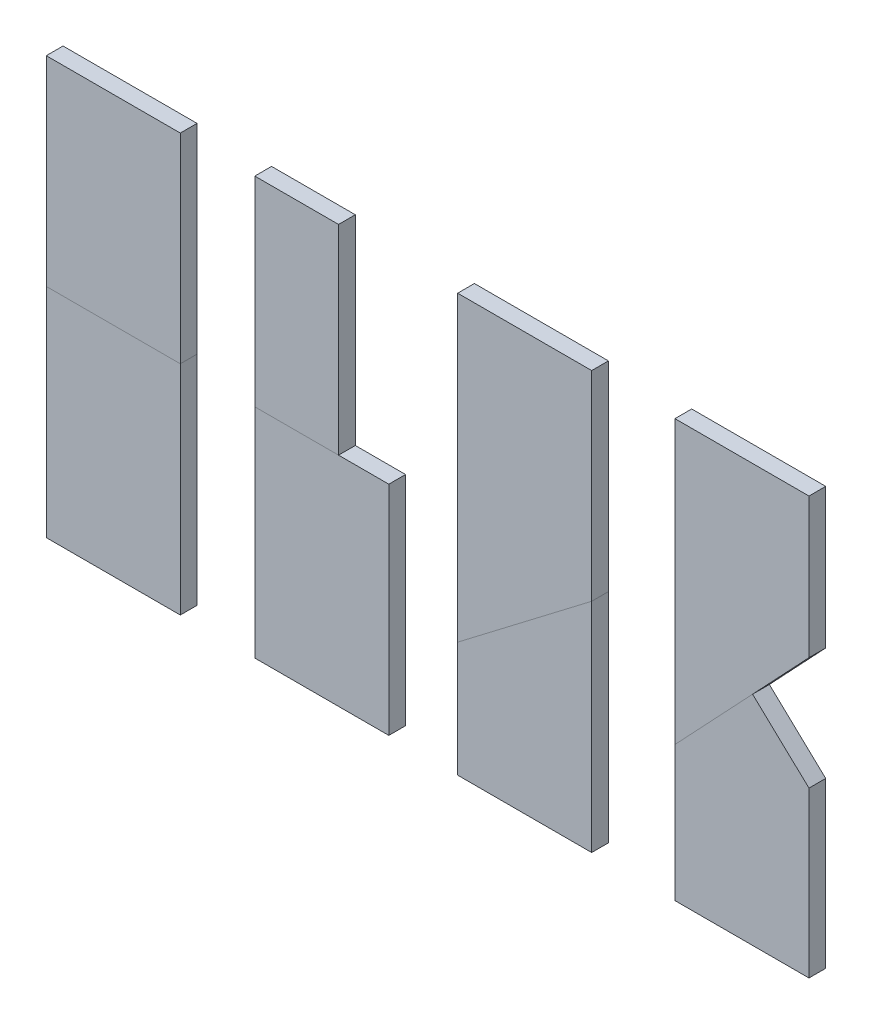
from build123d import *

# Parameters (mm, degrees)
ESQUISSE11_W                  = 40
ESQUISSE11_H                  = 5
EL_MENT_M_CANO_SOUD_1_DEPTH   = 59.639969087
ESQUISSE11_ON_SEGMENT_2_W     = 40
ESQUISSE11_ON_SEGMENT_2_H     = 5
EL_MENT_M_CANO_SOUD_1_2_DEPTH = 64.941299673
ESQUISSE12_W                  = 40
ESQUISSE12_H                  = 5
EL_MENT_M_CANO_SOUD_2_DEPTH   = 64.941299673
ESQUISSE14_W                  = 25
ESQUISSE14_H                  = 5
EL_MENT_M_CANO_SOUD_3_DEPTH   = 59.639969087
ESQUISSE15_W                  = 40
ESQUISSE15_H                  = 5
EL_MENT_M_CANO_SOUD_4_DEPTH   = 59.639969087
ESQUISSE15_ON_SEGMENT_2_W     = 40
ESQUISSE15_ON_SEGMENT_2_H     = 5
EL_MENT_M_CANO_SOUD_4_2_DEPTH = 64.941299673
ESQUISSE16_W                  = 40
ESQUISSE16_H                  = 5
EL_MENT_M_CANO_SOUD_5_DEPTH   = 59.639969087
ESQUISSE16_ON_SEGMENT_2_W     = 40
ESQUISSE16_ON_SEGMENT_2_H     = 5
EL_MENT_M_CANO_SOUD_5_2_DEPTH = 64.941299673
ENL_V_MAT_EXTRU_1_DEPTH       = 6
BOSS_EXTRU_1_DEPTH            = 5
ENL_V_MAT_EXTRU_3_DEPTH       = 6
BOSS_EXTRU_3_DEPTH            = 5


with BuildPart() as part:
    # Esquisse11 → El_ment m_cano-soud_1 (new body)
    with BuildSketch(Plane(origin=(-88.443865269, 59.639969087, 0), x_dir=(1, 0, 0), z_dir=(0, -1, 0))):
        Rectangle(ESQUISSE11_W, ESQUISSE11_H)
    extrude(amount=EL_MENT_M_CANO_SOUD_1_DEPTH)


with BuildPart() as body_2:
    # Esquisse11 on segment 2 (carried to segment 2) → El_ment m_cano-soud_1 2 (new body)
    with BuildSketch(Plane(origin=(-88.443865269, 0, 0), x_dir=(1, 0, 0), z_dir=(0, -1, 0))):
        Rectangle(ESQUISSE11_ON_SEGMENT_2_W, ESQUISSE11_ON_SEGMENT_2_H)
    extrude(amount=EL_MENT_M_CANO_SOUD_1_2_DEPTH)


with BuildPart() as body_3:
    # Esquisse12 → El_ment m_cano-soud_2 (new body)
    with BuildSketch(Plane(origin=(-26.209931604, -64.941299673, 0), x_dir=(-1, 0, 0), z_dir=(0, 1, 0))):
        Rectangle(ESQUISSE12_W, ESQUISSE12_H)
    extrude(amount=EL_MENT_M_CANO_SOUD_2_DEPTH)


with BuildPart() as body_4:
    # Esquisse14 → El_ment m_cano-soud_3 (new body)
    with BuildSketch(Plane(origin=(-33.709931604, 0, 0), x_dir=(-1, 0, 0), z_dir=(0, 1, 0))):
        Rectangle(ESQUISSE14_W, ESQUISSE14_H)
    extrude(amount=EL_MENT_M_CANO_SOUD_3_DEPTH)


with BuildPart() as body_5:
    # Esquisse15 → El_ment m_cano-soud_4 (new body)
    with BuildSketch(Plane(origin=(34.333341249, 59.639969087, 0), x_dir=(1, 0, 0), z_dir=(0, -1, 0))):
        Rectangle(ESQUISSE15_W, ESQUISSE15_H)
    extrude(amount=EL_MENT_M_CANO_SOUD_4_DEPTH)

    # Esquisse17_2 → Boss.-Extru.1 (add)
    with BuildSketch(Plane.XY.offset(2.5)):
        Polygon((14.333341249, 0), (14.333341249, -30.562858598), (54.333341249, 0), align=None)
    extrude(amount=-BOSS_EXTRU_1_DEPTH)


with BuildPart() as body_6:
    # Esquisse15 on segment 2 (carried to segment 2) → El_ment m_cano-soud_4 2 (new body)
    with BuildSketch(Plane(origin=(34.333341249, 0, 0), x_dir=(1, 0, 0), z_dir=(0, -1, 0))):
        Rectangle(ESQUISSE15_ON_SEGMENT_2_W, ESQUISSE15_ON_SEGMENT_2_H)
    extrude(amount=EL_MENT_M_CANO_SOUD_4_2_DEPTH)

    # Esquisse17 → Enl_v. mat.-Extru.1 (cut, through all)
    with BuildSketch(Plane.XY.offset(2.5)):
        Polygon((14.333341249, 0), (14.333341249, -30.562858598), (54.333341249, 0), align=None)
    extrude(amount=-ENL_V_MAT_EXTRU_1_DEPTH, mode=Mode.SUBTRACT)


with BuildPart() as body_7:
    # Esquisse16 → El_ment m_cano-soud_5 (new body)
    with BuildSketch(Plane(origin=(99.188796365, 59.639969087, 0), x_dir=(1, 0, 0), z_dir=(0, -1, 0))):
        Rectangle(ESQUISSE16_W, ESQUISSE16_H)
    extrude(amount=EL_MENT_M_CANO_SOUD_5_DEPTH)


with BuildPart() as body_8:
    # Esquisse16 on segment 2 (carried to segment 2) → El_ment m_cano-soud_5 2 (new body)
    with BuildSketch(Plane(origin=(99.188796365, 0, 0), x_dir=(1, 0, 0), z_dir=(0, -1, 0))):
        Rectangle(ESQUISSE16_ON_SEGMENT_2_W, ESQUISSE16_ON_SEGMENT_2_H)
    extrude(amount=EL_MENT_M_CANO_SOUD_5_2_DEPTH)


with BuildPart() as enl_v_mat_extru_3_tool:
    # Esquisse19 → Enl_v. mat.-Extru.3 (new body, through all)
    with BuildSketch(Plane.XY.offset(2.5)):
        Polygon((79.188796365, 17.858360365), (79.188796365, -24.591353025), (102.361016916, 0), (119.188796365, -15.856671912), (119.188796365, 17.858360365), align=None)
    extrude(amount=-ENL_V_MAT_EXTRU_3_DEPTH)


with BuildPart() as body_7_1:
    add(body_7.part)

    # Enl_v. mat.-Extru.3: cut by enl_v_mat_extru_3_tool
    add(enl_v_mat_extru_3_tool.part, mode=Mode.SUBTRACT)

    # Esquisse21 → Boss.-Extru.3 (add)
    with BuildSketch(Plane.XY.offset(2.5)):
        Polygon((79.188796365, 17.858360365), (79.188796365, -24.591353025), (119.188796365, 17.858360365), align=None)
    extrude(amount=-BOSS_EXTRU_3_DEPTH)


with BuildPart() as body_8_1:
    add(body_8.part)

    # Enl_v. mat.-Extru.3: cut by enl_v_mat_extru_3_tool
    add(enl_v_mat_extru_3_tool.part, mode=Mode.SUBTRACT)


solid = Compound([part.part, body_2.part, body_3.part, body_4.part, body_5.part, body_6.part, body_7_1.part, body_8_1.part])
